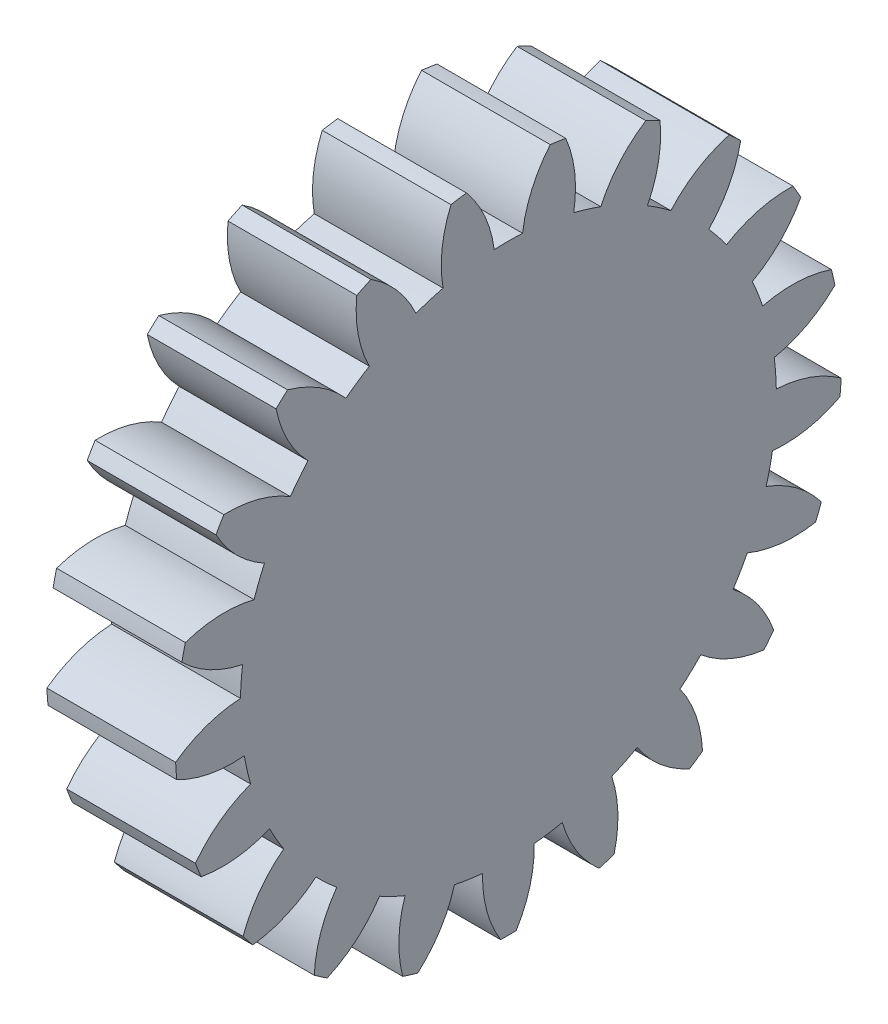
from build123d import *

# Parameters (mm, degrees)
BASPROSKE_W         = 10
BASPROSKE_H         = 25.875
TOOTHCUT_DEPTH      = 38.934565372
TEETHCUTS_COUNT     = 21
TEETHCUTS_ANGLE     = 342.857142857
BORSKE_R            = 11
BORE_DEPTH          = 50.0000508
SKETCH2_R           = 11
BOSS_EXTRUDE2_DEPTH = 3


with BuildPart() as part:
    # BasProSke → Base-Revolve (revolve)
    with BuildSketch(Plane(origin=(0, 0, 0), x_dir=(1, 0, 0), z_dir=(0, 1, 0)), mode=Mode.PRIVATE) as base_revolve_sk:
        with Locations((5, 12.9375)):
            Rectangle(BASPROSKE_W, BASPROSKE_H)
    revolve(base_revolve_sk.sketch.rotate(Axis((-10, 0, 0), (1, 0, 0)), 180), axis=Axis((-10, 0, 0), (1, 0, 0)))

    # TooCutSke → ToothCut (cut, through all)
    with BuildSketch(Plane(origin=(0, 0, 0), x_dir=(0, 0, -1), z_dir=(1, 0, 0))):
        with BuildLine():
            ThreePointArc((1.101400125, 20.782335047), (0, 20.8115), (-1.101400125, 20.782335047))
            ThreePointArc((-1.101400125, 20.782335047), (-1.83071474, 23.395008735), (-3.272169586, 25.692871119))
            ThreePointArc((-3.272169586, 25.692871119), (0, 25.9004), (3.272169586, 25.692871119))
            ThreePointArc((3.272169586, 25.692871119), (1.83071474, 23.395008735), (1.101400125, 20.782335047))
        make_face()
    toothcut = extrude(amount=TOOTHCUT_DEPTH, mode=Mode.SUBTRACT)

    # TeethCuts: ToothCut ×21 about axis
    teethcuts_axis = Axis((-10, 0, 0), (1, 0, 0))
    for i in range(1, TEETHCUTS_COUNT):
        add(toothcut.rotate(teethcuts_axis, i * TEETHCUTS_ANGLE / (TEETHCUTS_COUNT - 1)), mode=Mode.SUBTRACT)

    # BorSke → Bore (cut, symmetric)
    with BuildSketch(Plane(origin=(0, 0, 0), x_dir=(0, 0, -1), z_dir=(1, 0, 0))):
        with Locations(Location((0, 0, 0), (0, 0, 180))):
            Circle(BORSKE_R)
    extrude(amount=BORE_DEPTH, both=True, mode=Mode.SUBTRACT)

    # Sketch2 → Boss-Extrude2 (add)
    with BuildSketch(Plane(origin=(10, 0, 0), x_dir=(0, 0, -1), z_dir=(1, 0, 0))):
        Circle(SKETCH2_R)
    extrude(amount=-BOSS_EXTRUDE2_DEPTH)


solid = part.part
